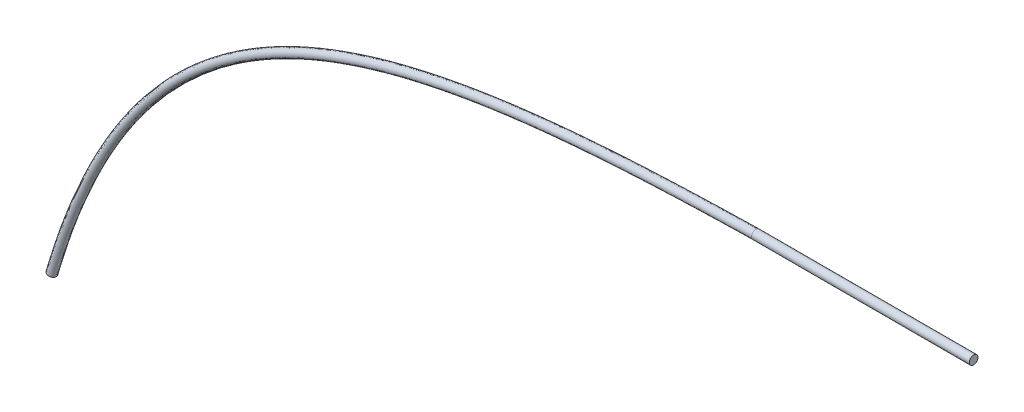
from build123d import *

# Parameters (mm, degrees)
EXTRUDE1_DEPTH = 12.7
SKETCH6_R      = 0.254


with BuildPart() as part:
    # Sketch1 → Extrude1 (new body)
    with BuildSketch(Plane(origin=(9.356672019, 0.000463605, 0), x_dir=(0, 0, 1), z_dir=(-0.9999999987724971, -4.9548017672609856e-05, 0))):
        with BuildLine():
            ThreePointArc((12.339722244, 22.836472421), (12.593722244, 22.582472421), (12.847722244, 22.836472421))
            Line((12.847722244, 22.836472421), (12.339722244, 22.836472421))
        make_face()
        with BuildLine():
            Line((12.339722244, 22.836472421), (12.847722244, 22.836472421))
            ThreePointArc((12.847722244, 22.836472421), (12.593722244, 23.090472421), (12.339722244, 22.836472421))
        make_face()
    extrude(amount=-EXTRUDE1_DEPTH)

    # Sweep1: sweep along a path in Sketch5
    with BuildLine() as sweep1_path:  # in the path sketch's own coordinates; laid on its plane below (add() does not lay a ready-made edge on the line's plane)
        add(Edge.make_bspline(
            [(-9.355540517, 22.836935998), (12.1217357, 22.414993465), (26.007079458, 19.897094592), (31.703419359, 0.358081519)],
            knots=[0, 0, 0, 0, 1, 1, 1, 1], degree=3))
    # Sketch6 → Sweep1 (sweep)
    with BuildSketch(Plane(origin=(9.356672019, 0.000463605, 0), x_dir=(0, 0, 1), z_dir=(-0.9999999987724971, -4.9548017672538895e-05, 0))):
        with Locations((12.593722244, 22.836472421)):
            Circle(SKETCH6_R)
    sweep(path=Plane(origin=(0, 0, 12.593722244), x_dir=(-1, 0, 0), z_dir=(0, 0, -1)) * sweep1_path.line)


solid = part.part
